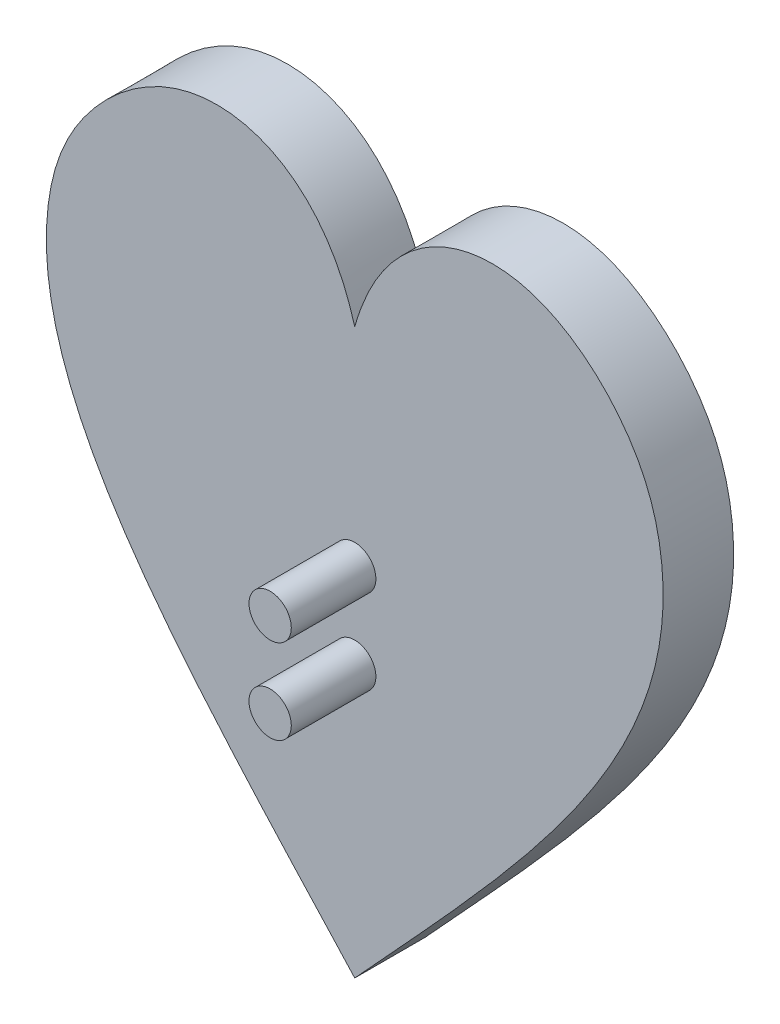
from build123d import *

# Parameters (mm, degrees)
BOSS_EXTRUDE1_DEPTH = 6.35
SKETCH2_R           = 1.905
BOSS_EXTRUDE2_DEPTH = 7.62


with BuildPart() as part:
    # Sketch1 → Boss-Extrude1 (new body)
    with BuildSketch(Plane.XY):
        with BuildLine():
            add(Edge.make_bspline(
                [(1.654594255, 28.637086731), (4.270876616, 37.994619502), (16.280234659, 43.248904234), (27.555962484, 32.352353304), (32.898473868, 10.57833674), (16.656735718, -5.779122619), (1.654594255, -22.162913269)],
                knots=[0, 0, 0, 0, 0.212199078, 0.359774349, 0.438554441, 1, 1, 1, 1], degree=3))
            add(Edge.make_bspline(
                [(1.654594255, 28.637086731), (-0.961688106, 37.994619502), (-12.971046149, 43.248904234), (-24.246773974, 32.352353304), (-29.589285358, 10.57833674), (-13.347547209, -5.779122619), (1.654594255, -22.162913269)],
                knots=[0, 0, 0, 0, 0.212199078, 0.359774349, 0.438554441, 1, 1, 1, 1], degree=3))
        make_face()
    extrude(amount=BOSS_EXTRUDE1_DEPTH)

    # Sketch2 → Boss-Extrude2 (add)
    with BuildSketch(Plane.XY.offset(6.35)):
        with Locations((1.654594255, 9.916109637)):
            Circle(SKETCH2_R)
        with Locations((1.654594255, 2.296109637)):
            Circle(SKETCH2_R)
    extrude(amount=BOSS_EXTRUDE2_DEPTH)


solid = part.part
